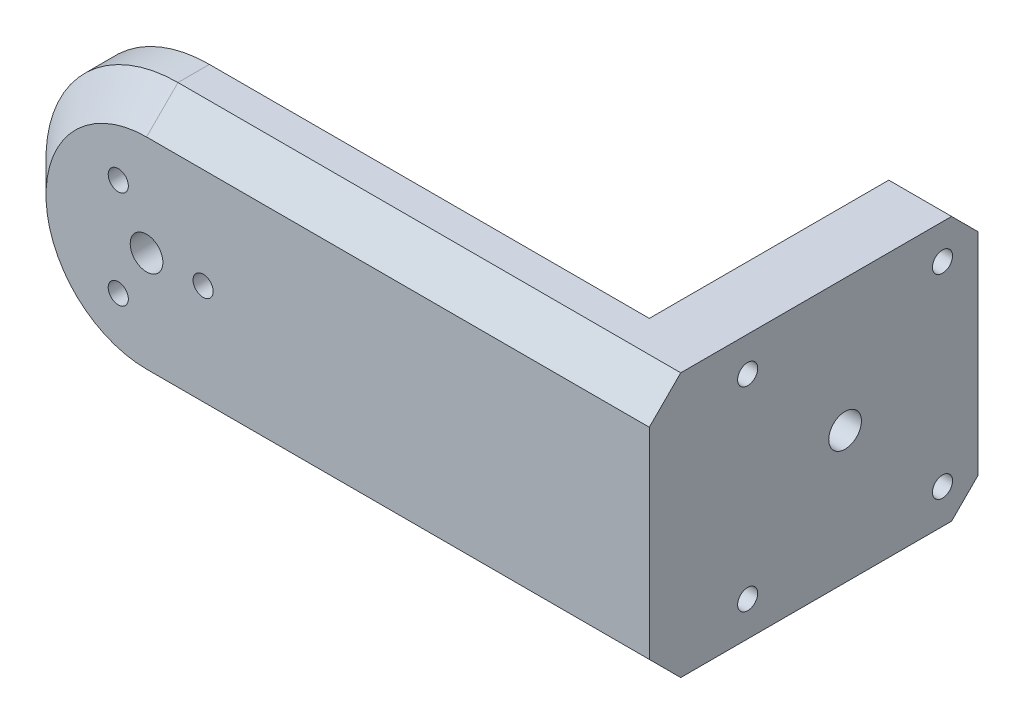
from build123d import *

# Parameters (mm, degrees)
SKETCH_1_R          = 12.5
SKETCH_1_R_2        = 1.6
EXTRUDE_1_DEPTH     = 11
SKETCH_2_R          = 12.5
EXTRUDE_2_DEPTH     = 10
SKETCH_3_W          = 52.3
SKETCH_3_H          = 42
EXTRUDE_3_DEPTH     = 10
SKETCH_6_R          = 2.6
CUT_EXTRUDE_1_DEPTH = 53.3
SKETCH_8_R          = 1.6
SKETCH_8_R_2        = 2.6
CUT_EXTRUDE_3_DEPTH = 11
SKETCH_9_R          = 11.5
CUT_EXTRUDE_4_DEPTH = 3
CHAMFER_1_SIZE      = 5
CHAMFER_2_SIZE      = 4.2


with BuildPart() as part:
    # 草图1 → 凸台-拉伸1 (new body)
    with BuildSketch(Plane.XY):
        Circle(SKETCH_1_R)
        with Locations((9, 0)):
            Circle(SKETCH_1_R_2, mode=Mode.SUBTRACT)
        with Locations((-4.5, -7.794228634)):
            Circle(SKETCH_1_R_2, mode=Mode.SUBTRACT)
        with Locations((-4.5, 7.794228634)):
            Circle(SKETCH_1_R_2, mode=Mode.SUBTRACT)
    extrude(amount=EXTRUDE_1_DEPTH)

    # 草图2 → 凸台-拉伸2 (add)
    with BuildSketch(Plane.XY.offset(11)):
        with BuildLine():
            Line((0, 21), (70, 21))
            Line((70, 21), (70, -21))
            Line((70, -21), (0, -21))
            ThreePointArc((0, -21), (-21, 0), (0, 21))
        make_face()
        Circle(SKETCH_2_R, mode=Mode.SUBTRACT)
    extrude(amount=-EXTRUDE_2_DEPTH)

    # 草图3 → 凸台-拉伸3 (add)
    with BuildSketch(Plane(origin=(70, 0, 0), x_dir=(0, 0, -1), z_dir=(1, 0, 0))):
        with Locations((15.15, 0)):
            Rectangle(SKETCH_3_W, SKETCH_3_H)
    extrude(amount=EXTRUDE_3_DEPTH)

    # 草图6 → 切除-拉伸1 (cut, through all)
    with BuildSketch(Plane(origin=(0, 0, -41.3), x_dir=(-1, 0, 0), z_dir=(0, 0, -1))):
        Circle(SKETCH_6_R)
    extrude(amount=-CUT_EXTRUDE_1_DEPTH, mode=Mode.SUBTRACT)

    # 草图8 → 切除-拉伸3 (cut, through all)
    with BuildSketch(Plane.ZY.offset(-70)):
        with Locations((-35.65, 15.5)):
            Circle(SKETCH_8_R)
        with Locations((-4.65, 15.5)):
            Circle(SKETCH_8_R)
        with Locations((-4.65, -15.5)):
            Circle(SKETCH_8_R)
        with Locations((-35.65, -15.5)):
            Circle(SKETCH_8_R)
        with Locations((-20.15, 0)):
            Circle(SKETCH_8_R_2)
    extrude(amount=-CUT_EXTRUDE_3_DEPTH, mode=Mode.SUBTRACT)

    # 草图9 → 切除-拉伸4 (cut)
    with BuildSketch(Plane.ZY.offset(-70)):
        with Locations((-20.15, 0)):
            Circle(SKETCH_9_R)
    extrude(amount=-CUT_EXTRUDE_4_DEPTH, mode=Mode.SUBTRACT)

    # 倒角1
    chamfer_1_edges = [part.edges().sort_by_distance(p)[0] for p in [
        (-21, 0, 11),
        (40, -21, 11),
        (40, 21, 11),
    ]]
    chamfer(chamfer_1_edges, length=CHAMFER_1_SIZE)

    # 倒角2
    chamfer_2_edges = [part.edges().sort_by_distance(p)[0] for p in [
        (75, -21, -41.3),
        (75, 21, -41.3),
    ]]
    chamfer(chamfer_2_edges, length=CHAMFER_2_SIZE)


solid = part.part
